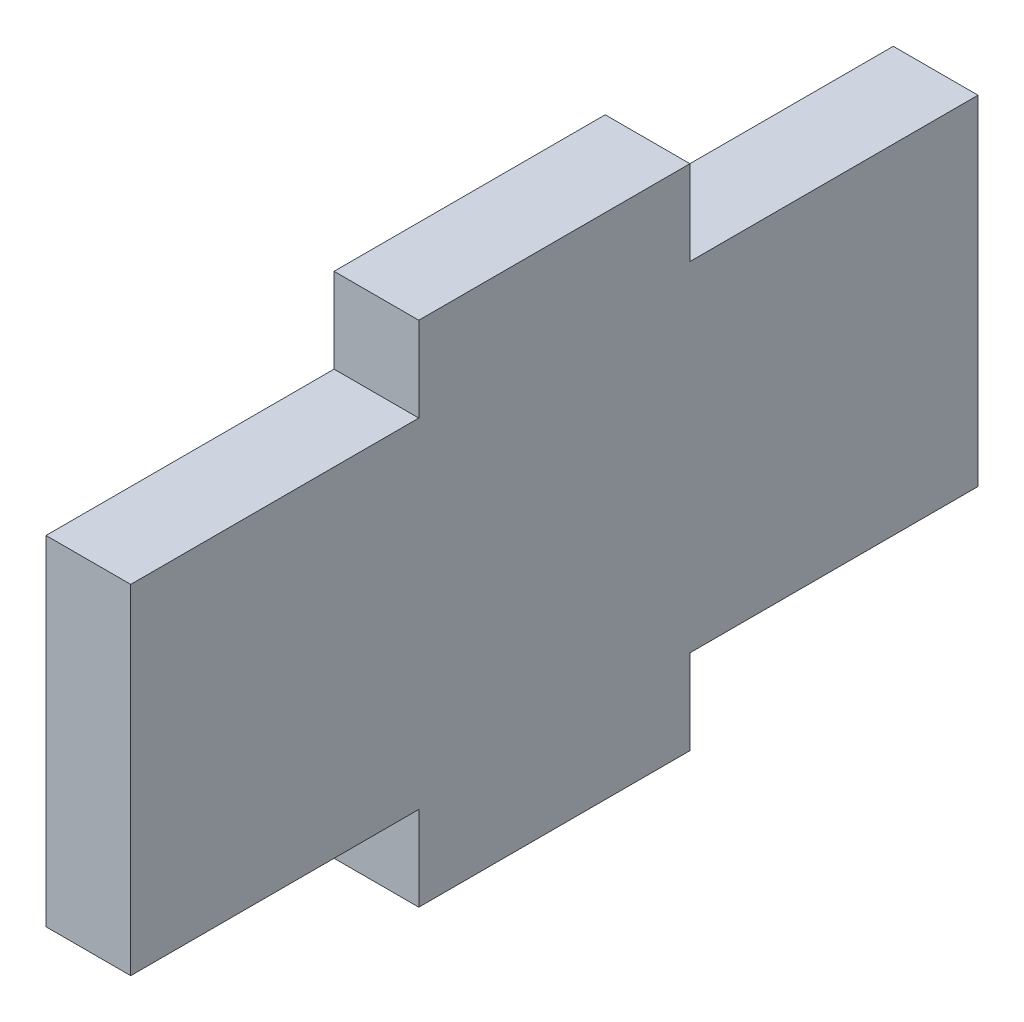
from build123d import *

# Parameters (mm, degrees)
BOSS_EXTRUDE1_DEPTH = 5


with BuildPart() as part:
    # Sketch1 → Boss-Extrude1 (new body)
    with BuildSketch(Plane(origin=(0, 0, 0), x_dir=(0, 0, -1), z_dir=(1, 0, 0))):
        Polygon((-8, 10), (-8, 15), (8, 15), (8, 10), (20, 10), (25, 10), (25, -10), (20, -10), (8, -10), (8, -15), (-8, -15), (-8, -10), (-20, -10), (-25, -10), (-25, 10), (-20, 10), align=None)
    extrude(amount=BOSS_EXTRUDE1_DEPTH)


solid = part.part
